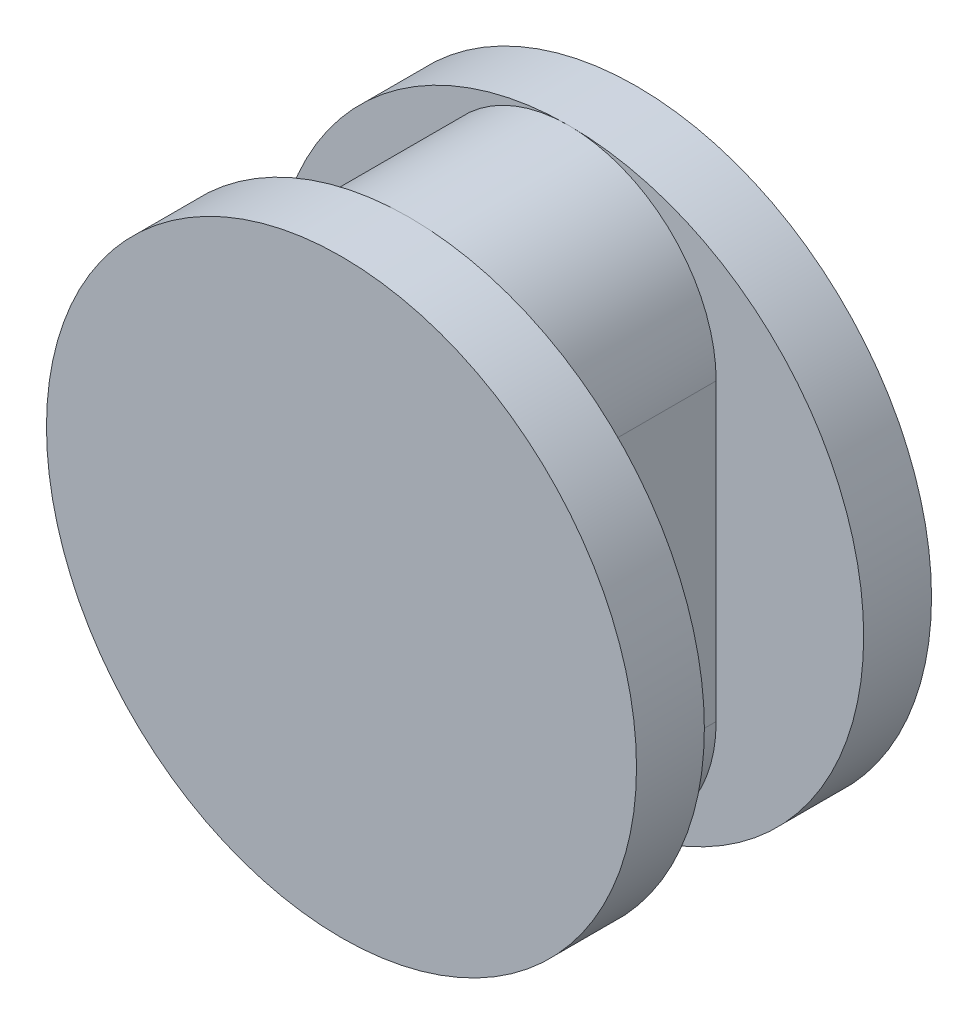
from build123d import *

# Parameters (mm, degrees)
DODANIE_WYCI_GNI_CIE1_DEPTH = 2.7
SZKIC2_R                    = 10
DODANIE_WYCI_GNI_CIE2_DEPTH = 2.3
DODANIE_WYCI_GNI_CIE3_DEPTH = 2.3


with BuildPart() as part:
    # Szkic1 → Dodanie-wyciągnięcie1 (new body, symmetric)
    with BuildSketch(Plane.XY):
        with BuildLine():
            Line((5, -10), (5, 0))
            ThreePointArc((5, 0), (0, 5), (-5, 0))
            Line((-5, 0), (-5, -10))
            ThreePointArc((-5, -10), (0, -15), (5, -10))
        make_face()
    extrude(amount=DODANIE_WYCI_GNI_CIE1_DEPTH, both=True)

    # Szkic2 → Dodanie-wyciągnięcie2 (add)
    with BuildSketch(Plane.XY.offset(2.7)):
        with Locations((0, -5)):
            Circle(SZKIC2_R)
    extrude(amount=DODANIE_WYCI_GNI_CIE2_DEPTH)

    # Szkic3 → Dodanie-wyciągnięcie3 (add)
    with BuildSketch(Plane(origin=(0, 0, -2.7), x_dir=(-1, 0, 0), z_dir=(0, 0, -1))):
        with BuildLine():
            Line((5, 0), (5, -10))
            ThreePointArc((5, -10), (3.535533906, -13.535533906), (0, -15))
            ThreePointArc((0, -15), (7.071067812, -12.071067812), (10, -5))
            ThreePointArc((10, -5), (7.071067812, 2.071067812), (0, 5))
            ThreePointArc((0, 5), (3.535533906, 3.535533906), (5, 0))
        make_face()
        with BuildLine():
            Line((-5, 0), (-5, -10))
            ThreePointArc((-5, -10), (0, -15), (5, -10))
            Line((5, -10), (5, 0))
            ThreePointArc((5, 0), (0, 5), (-5, 0))
        make_face()
        with BuildLine():
            ThreePointArc((0, 5), (-10, -5), (0, -15))
            ThreePointArc((0, -15), (-3.535533906, -13.535533906), (-5, -10))
            Line((-5, -10), (-5, 0))
            ThreePointArc((-5, 0), (-3.535533906, 3.535533906), (0, 5))
        make_face()
    extrude(amount=DODANIE_WYCI_GNI_CIE3_DEPTH)


solid = part.part
